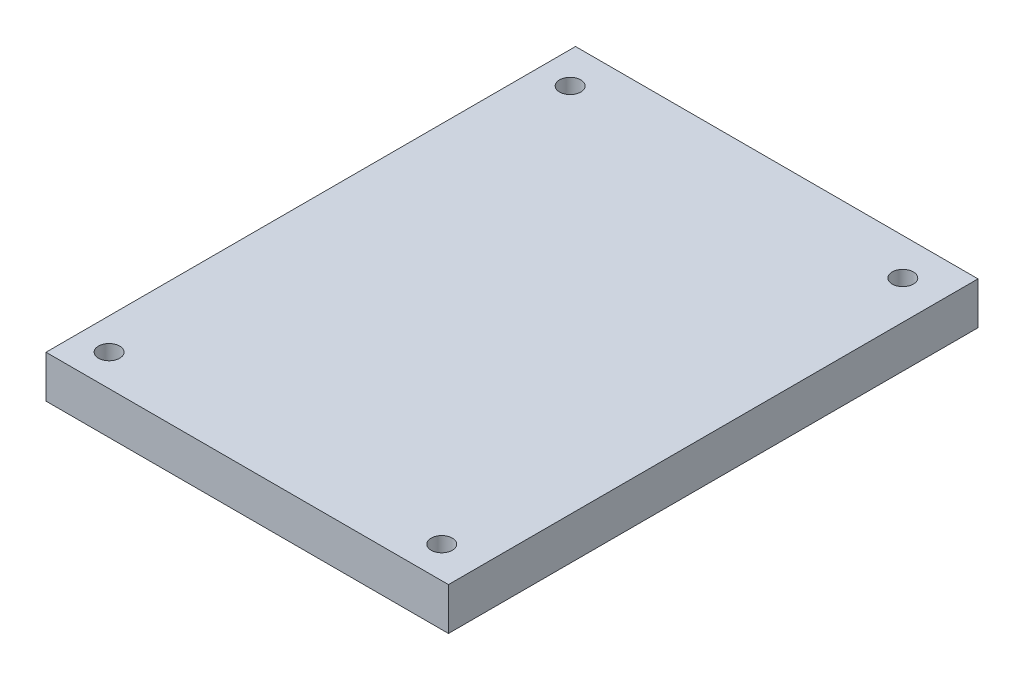
from build123d import *

# Parameters (mm, degrees)
IZIM1_W                     = 19
IZIM1_H                     = 25
IZIM1_R                     = 0.5
Y_KSEKLIK_EKSTR_ZYON1_DEPTH = 2


with BuildPart() as part:
    # Çizim1 → Yükseklik-Ekstrüzyon1 (new body)
    with BuildSketch(Plane(origin=(0, 0, 0), x_dir=(1, 0, 0), z_dir=(0, 1, 0))):
        with Locations((2.053191489, 2.859042553)):
            Rectangle(IZIM1_W, IZIM1_H)
        with Locations((-5.960760417, 13.619097396)):
            Circle(IZIM1_R, mode=Mode.SUBTRACT)
        with Locations((9.742944474, 13.619097396)):
            Circle(IZIM1_R, mode=Mode.SUBTRACT)
        with Locations((-5.960760417, -8.147814016)):
            Circle(IZIM1_R, mode=Mode.SUBTRACT)
        with Locations((9.742944474, -8.147814016)):
            Circle(IZIM1_R, mode=Mode.SUBTRACT)
    extrude(amount=Y_KSEKLIK_EKSTR_ZYON1_DEPTH)


solid = part.part
